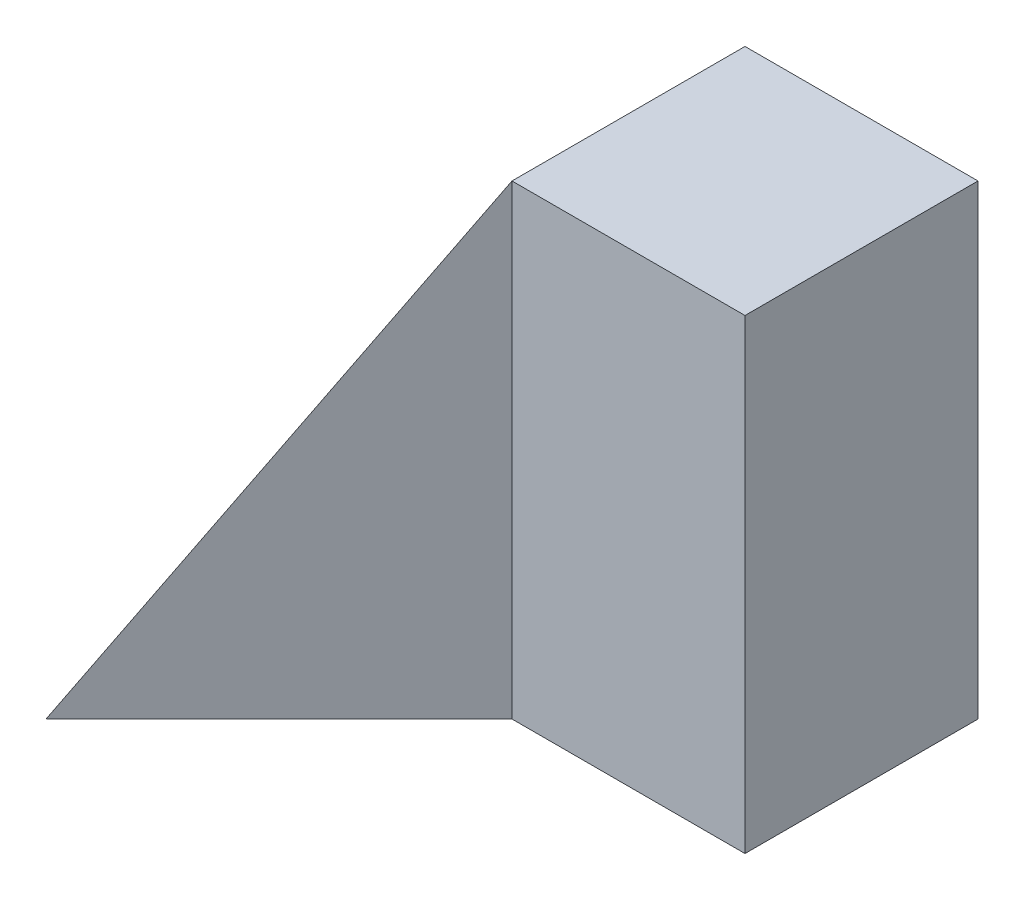
from build123d import *

# Parameters (mm, degrees)
SKETCH1_W           = 40
SKETCH1_H           = 40
BOSS_EXTRUDE1_DEPTH = 40
CUT_EXTRUDE1_DEPTH  = 40
CUT_EXTRUDE2_DEPTH  = 40


with BuildPart() as part:
    # Sketch1 → Boss-Extrude1 (new body)
    with BuildSketch(Plane.XY):
        with Locations((20, 20)):
            Rectangle(SKETCH1_W, SKETCH1_H)
    extrude(amount=BOSS_EXTRUDE1_DEPTH)

    # Sketch2 → Cut-Extrude1 (cut)
    with BuildSketch(Plane.XY.offset(40)):
        Polygon((0, 0), (20, 40), (0, 40), align=None)
    extrude(amount=-CUT_EXTRUDE1_DEPTH, mode=Mode.SUBTRACT)

    # Sketch3 → Cut-Extrude2 (cut)
    with BuildSketch(Plane.XZ):
        Polygon((40, 20), (20, 20), (0, 40), (40, 40), align=None)
    extrude(amount=-CUT_EXTRUDE2_DEPTH, mode=Mode.SUBTRACT)


solid = part.part
